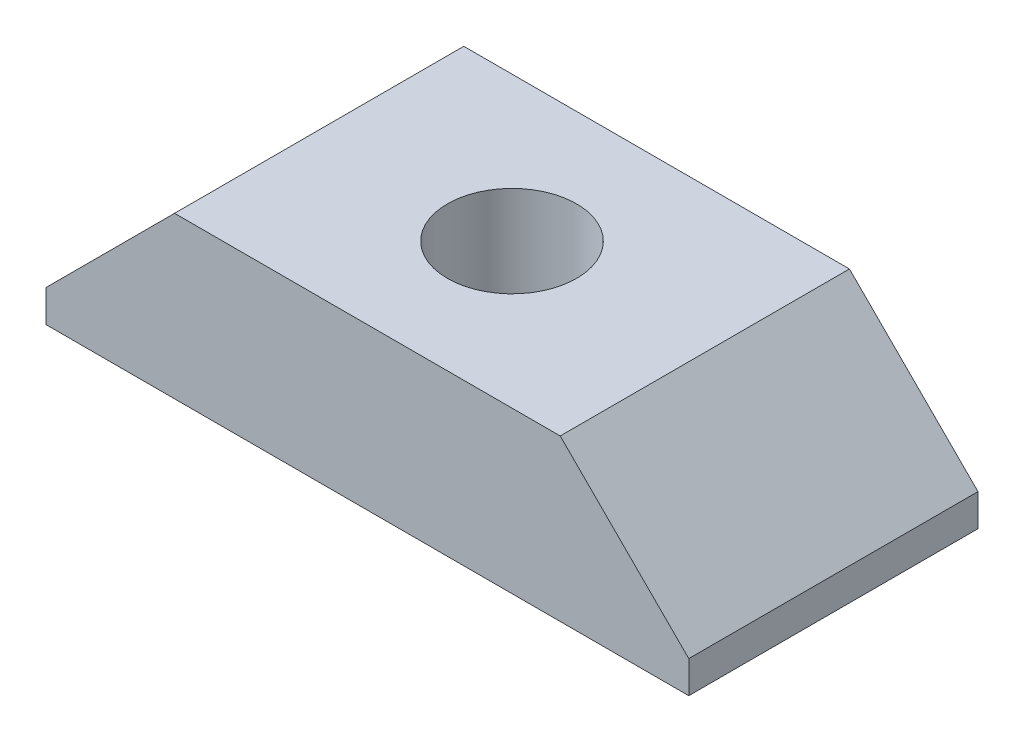
from build123d import *

# Parameters (mm, degrees)
SKETCH1_W               = 25.4
SKETCH1_H               = 6.35
BOSS_EXTRUDE1_DEPTH     = 11.43
CHAMFER2_SIZE           = 5.08
F_1_4_20_TAPPED_HOLE1_D = 5.1054


with BuildPart() as part:
    # Sketch1 → Boss-Extrude1 (new body)
    with BuildSketch(Plane.XY):
        Rectangle(SKETCH1_W, SKETCH1_H)
    extrude(amount=BOSS_EXTRUDE1_DEPTH)

    # Chamfer2
    chamfer2_edges = [part.edges().sort_by_distance(p)[0] for p in [
        (-12.7, 3.175, 5.715),
        (12.7, 3.175, 5.715),
    ]]
    chamfer(chamfer2_edges, length=CHAMFER2_SIZE)

    # 1/4-20 Tapped Hole1 (through all)
    with Locations(Plane(origin=(0, 3.175, 0), x_dir=(-1, 0, 0), z_dir=(0, 1, 0))):
        with Locations((0, 5.715)):
            Hole(F_1_4_20_TAPPED_HOLE1_D / 2)


solid = part.part
